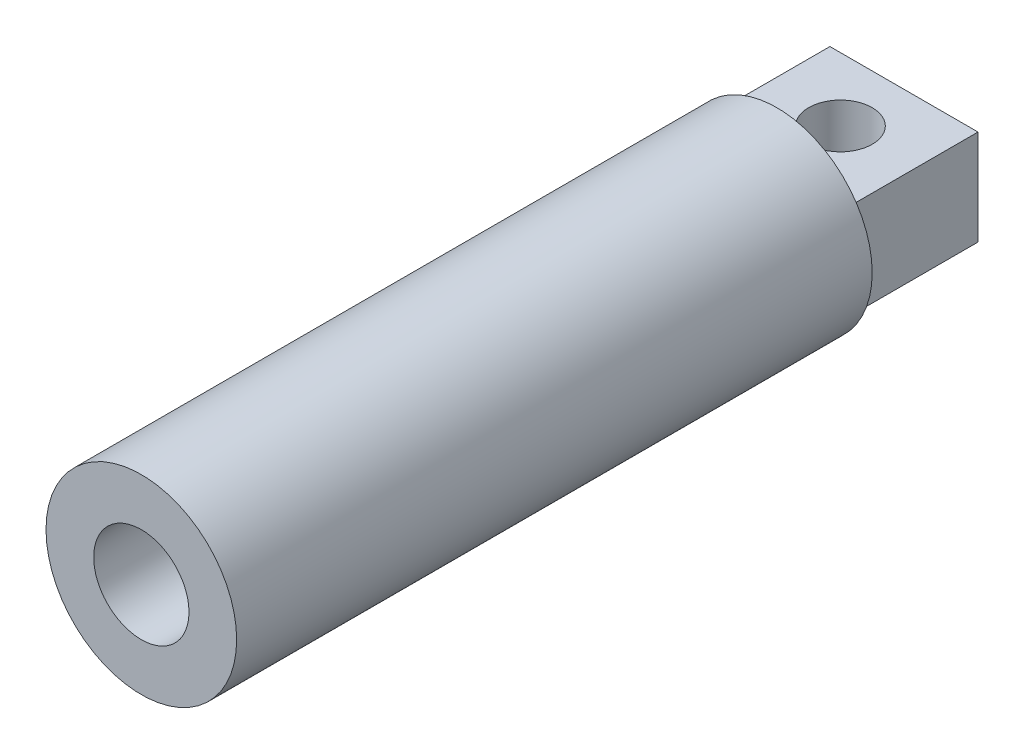
from build123d import *

# Parameters (mm, degrees)
SKETCH1_R           = 15
BOSS_EXTRUDE1_DEPTH = 100
SKETCH2_R           = 7.5
CUT_EXTRUDE1_DEPTH  = 130
SKETCH3_W           = 23.300503328
SKETCH3_H           = 40
SKETCH3_R           = 5
BOSS_EXTRUDE2_DEPTH = 7.5


with BuildPart() as part:
    # Sketch1 → Boss-Extrude1 (new body)
    with BuildSketch(Plane.XY):
        Circle(SKETCH1_R)
    extrude(amount=BOSS_EXTRUDE1_DEPTH)

    # Sketch2 → Cut-Extrude1 (cut)
    with BuildSketch(Plane.XY.offset(100)):
        Circle(SKETCH2_R)
    extrude(amount=-CUT_EXTRUDE1_DEPTH, mode=Mode.SUBTRACT)

    # Sketch3 → Boss-Extrude2 (add, symmetric)
    with BuildSketch(Plane(origin=(0, 0, 0), x_dir=(1, 0, 0), z_dir=(0, 1, 0))):
        Rectangle(SKETCH3_W, SKETCH3_H)
        with Locations((0, 10)):
            Circle(SKETCH3_R, mode=Mode.SUBTRACT)
    extrude(amount=BOSS_EXTRUDE2_DEPTH, both=True)


solid = part.part
